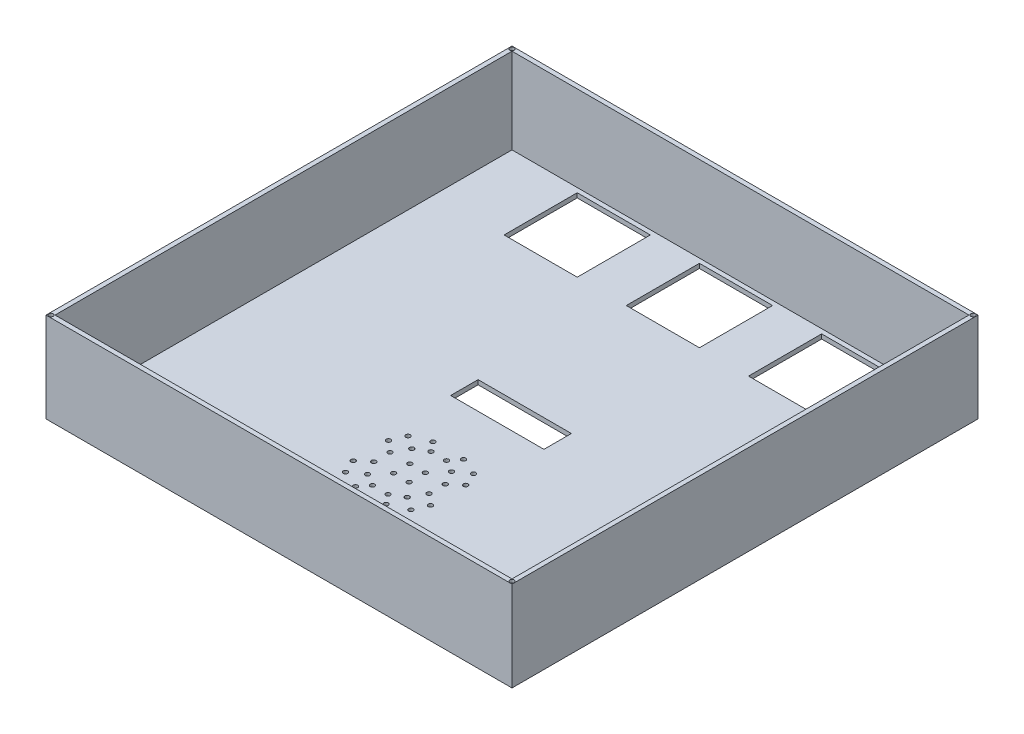
from build123d import *

# Parameters (mm, degrees)
SKETCH2_W           = 51.8
SKETCH2_H           = 51.8
BOSS_EXTRUDE1_DEPTH = 20
SKETCH3_W           = 50.8
SKETCH3_H           = 50.8
CUT_EXTRUDE1_DEPTH  = 19.5
SKETCH4_W           = 8.13
SKETCH4_H           = 8.13
SKETCH4_W_2         = 8.128
SKETCH4_H_2         = 8.128
SKETCH4_W_3         = 10.368
SKETCH4_H_3         = 3.05
SKETCH4_R           = 0.25
CUT_EXTRUDE2_DEPTH  = 83.389322432
SKETCH4_3_R         = 0.25
CUT_EXTRUDE3_DEPTH  = 19.5
SKETCH5_W           = 51.8
SKETCH5_H           = 10
CUT_EXTRUDE4_DEPTH  = 81.870622457
SKETCH6_R           = 0.25
CUT_EXTRUDE8_DEPTH  = 2


with BuildPart() as part:
    # Sketch2 → Boss-Extrude1 (new body)
    with BuildSketch(Plane(origin=(0, 10, 0), x_dir=(1, 0, 0), z_dir=(0, 1, 0))):
        with Locations((28.476627116, 32.676299595)):
            Rectangle(SKETCH2_W, SKETCH2_H)
    extrude(amount=BOSS_EXTRUDE1_DEPTH)

    # Sketch3 → Cut-Extrude1 (cut)
    with BuildSketch(Plane(origin=(0, 30, 0), x_dir=(1, 0, 0), z_dir=(0, 1, 0))):
        with Locations((28.476627116, 32.676299595)):
            Rectangle(SKETCH3_W, SKETCH3_H)
    extrude(amount=-CUT_EXTRUDE1_DEPTH, mode=Mode.SUBTRACT)

    # Sketch4 → Cut-Extrude2 (cut, through all)
    with BuildSketch(Plane.XZ.offset(-10)):
        with Locations((28.475627116, -53.511299595)):
            Rectangle(SKETCH4_W, SKETCH4_H)
        with Locations((14.890627116, -53.512299595)):
            Rectangle(SKETCH4_W_2, SKETCH4_H_2)
        with Locations((28.492627116, -32.551299595)):
            Rectangle(SKETCH4_W_3, SKETCH4_H_3)
        with Locations((42.061627116, -53.511299595)):
            Rectangle(SKETCH4_W, SKETCH4_H)
        with Locations((24.842150221, -24.757567746)):
            Circle(SKETCH4_R)
        with Locations((31.547423124, -22.183425025)):
            Circle(SKETCH4_R)
        with Locations((29.340042817, -22.183425025)):
            Circle(SKETCH4_R)
        with Locations((27.613211416, -24.53053501)):
            Circle(SKETCH4_R)
        with Locations((25.405831109, -22.183425025)):
            Circle(SKETCH4_R)
        with Locations((27.613211416, -22.183425025)):
            Circle(SKETCH4_R)
        with Locations((26.270141803, -23.742942148)):
            Circle(SKETCH4_R)
        with Locations((24.184522519, -23.235629349)):
            Circle(SKETCH4_R)
        with Locations((26.777454602, -25.584299714)):
            Circle(SKETCH4_R)
        with Locations((32.111104012, -17.803671149)):
            Circle(SKETCH4_R)
        with Locations((25.405831109, -20.377813869)):
            Circle(SKETCH4_R)
        with Locations((30.175799631, -25.584299714)):
            Circle(SKETCH4_R)
        with Locations((32.111104012, -24.757567746)):
            Circle(SKETCH4_R)
        with Locations((29.340042817, -24.53053501)):
            Circle(SKETCH4_R)
        with Locations((30.68311243, -23.742942148)):
            Circle(SKETCH4_R)
        with Locations((32.768731714, -23.235629349)):
            Circle(SKETCH4_R)
        with Locations((26.270141803, -18.818296747)):
            Circle(SKETCH4_R)
        with Locations((27.613211416, -18.030703885)):
            Circle(SKETCH4_R)
        with Locations((29.340042817, -20.377813869)):
            Circle(SKETCH4_R)
        with Locations((31.547423124, -20.377813869)):
            Circle(SKETCH4_R)
        with Locations((30.68311243, -18.818296747)):
            Circle(SKETCH4_R)
        with Locations((29.340042817, -18.030703885)):
            Circle(SKETCH4_R)
        with Locations((30.175799631, -16.97693918)):
            Circle(SKETCH4_R)
        with Locations((24.842150221, -17.803671149)):
            Circle(SKETCH4_R)
        with Locations((26.777454602, -16.97693918)):
            Circle(SKETCH4_R)
        with Locations((24.184522519, -19.325609546)):
            Circle(SKETCH4_R)
    extrude(amount=-CUT_EXTRUDE2_DEPTH, mode=Mode.SUBTRACT)

    # Sketch4_3 → Cut-Extrude3 (cut)
    with BuildSketch(Plane.XZ.offset(-10)):
        with Locations((27.613211416, -20.377813869)):
            Circle(SKETCH4_3_R)
        with Locations((32.768731714, -19.325609546)):
            Circle(SKETCH4_3_R)
    extrude(amount=-CUT_EXTRUDE3_DEPTH, mode=Mode.SUBTRACT)

    # Sketch5 → Cut-Extrude4 (cut, through all)
    with BuildSketch(Plane(origin=(0, 0, -58.576299595), x_dir=(-1, 0, 0), z_dir=(0, 0, -1))):
        with Locations((-28.476627116, 25)):
            Rectangle(SKETCH5_W, SKETCH5_H)
    extrude(amount=-CUT_EXTRUDE4_DEPTH, mode=Mode.SUBTRACT)

    # Sketch6 → Cut-Extrude8 (cut)
    with BuildSketch(Plane(origin=(0, 20, 0), x_dir=(1, 0, 0), z_dir=(0, 1, 0))):
        with Locations((2.852996887, 58.299929824)):
            Circle(SKETCH6_R)
        with Locations((54.100257345, 58.299929824)):
            Circle(SKETCH6_R)
        with Locations((54.100257345, 7.052669366)):
            Circle(SKETCH6_R)
        with Locations((2.852996887, 7.052669366)):
            Circle(SKETCH6_R)
    extrude(amount=-CUT_EXTRUDE8_DEPTH, mode=Mode.SUBTRACT)


solid = part.part
